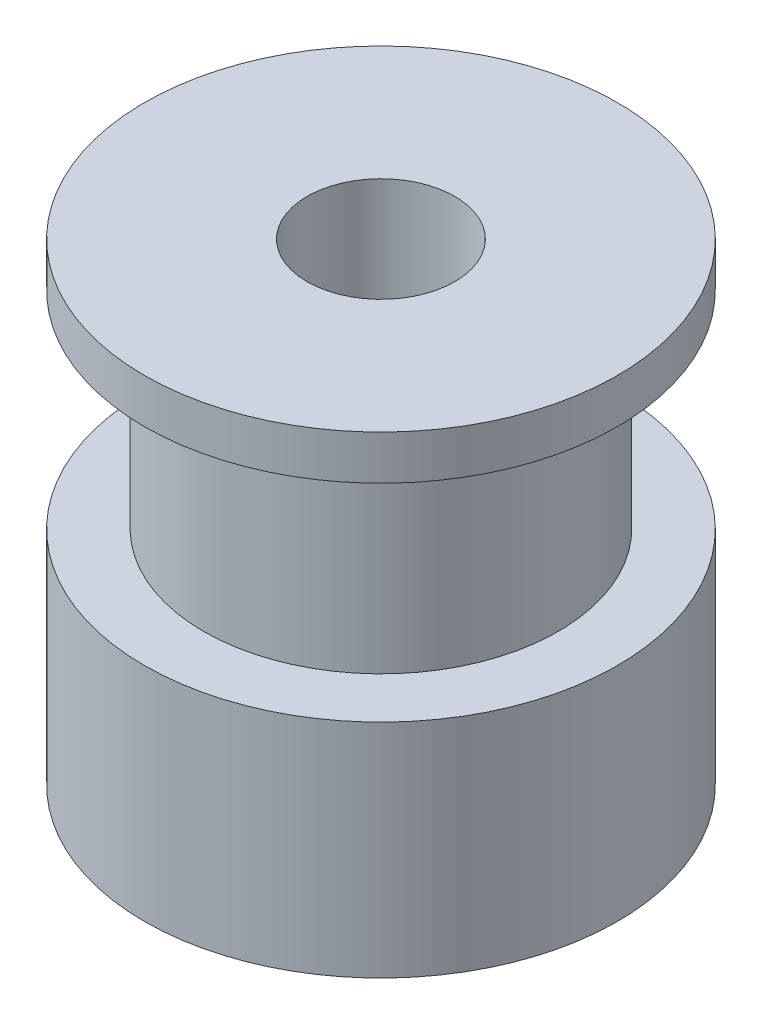
from build123d import *


with BuildPart() as part:
    # Esboço1 → Revolução1 (revolve)
    with BuildSketch(Plane.XY):
        Polygon((2.5, 16), (8, 16), (8, 14.5), (6, 14.5), (6, 7.5), (8, 7.5), (8, 0), (2.5, 0), align=None)
    revolve(axis=Axis((0, 15.012358039, 0), (0, -1, 0)))


solid = part.part
